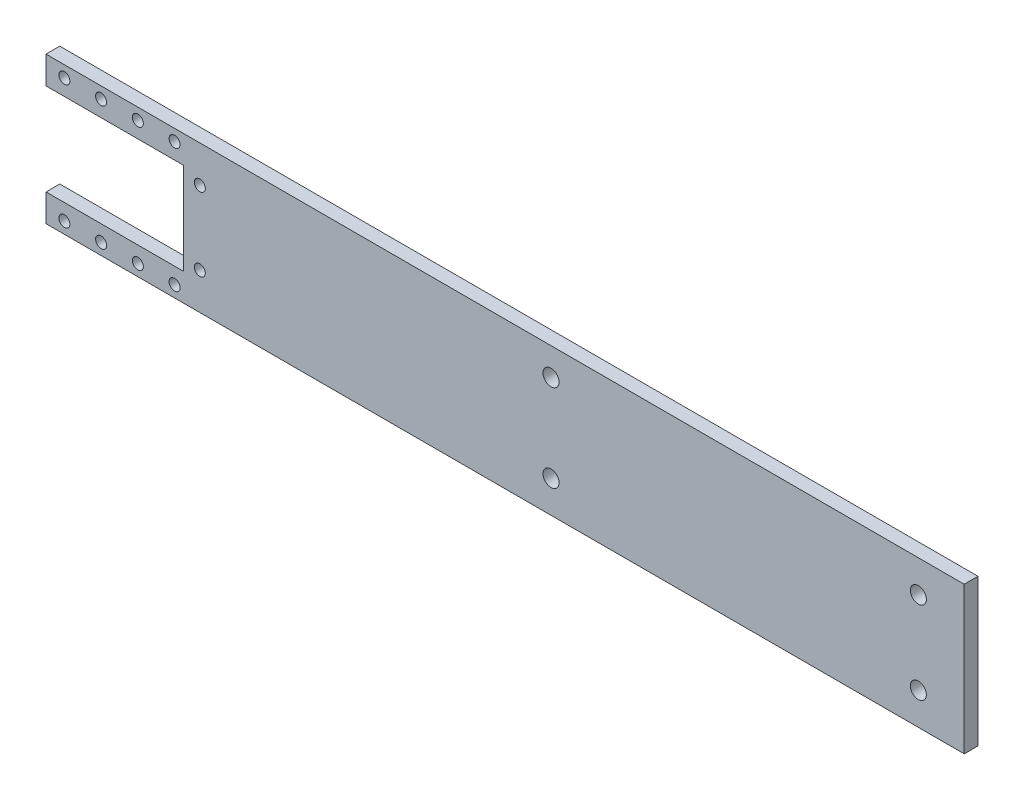
from build123d import *

# Parameters (mm, degrees)
BOSS_EXTRUDE1_DEPTH        = 3
M2_CLEARANCE_HOLE1_D       = 2.4
F_3_5_3_5_DIAMETER_HOLE1_D = 3.5


with BuildPart() as part:
    # Sketch1 → Boss-Extrude1 (new body)
    with BuildSketch(Plane.XY):
        Polygon((-17.75, 16), (182.25, 16), (182.25, -16), (-17.75, -16), (-17.75, -10), (12.25, -10), (12.25, 10), (-17.75, 10), align=None)
    extrude(amount=BOSS_EXTRUDE1_DEPTH)

    # M2 Clearance Hole1 (through all)
    with Locations(Plane.XY.offset(3)):
        with Locations((-13.75, 13.5), (-5.75, 13.5), (2.25, 13.5), (10.25, 13.5), (15.75, 8), (15.75, -8), (10.25, -13.5), (2.25, -13.5), (-5.75, -13.5), (-13.75, -13.5)):
            Hole(M2_CLEARANCE_HOLE1_D / 2)

    # Ø3.5 (3.5) Diameter Hole1 (through all)
    with Locations(Plane.XY.offset(3)):
        with Locations((92.25, -9), (92.25, 10), (172.25, 9), (172.25, -9)):
            Hole(F_3_5_3_5_DIAMETER_HOLE1_D / 2)


solid = part.part
